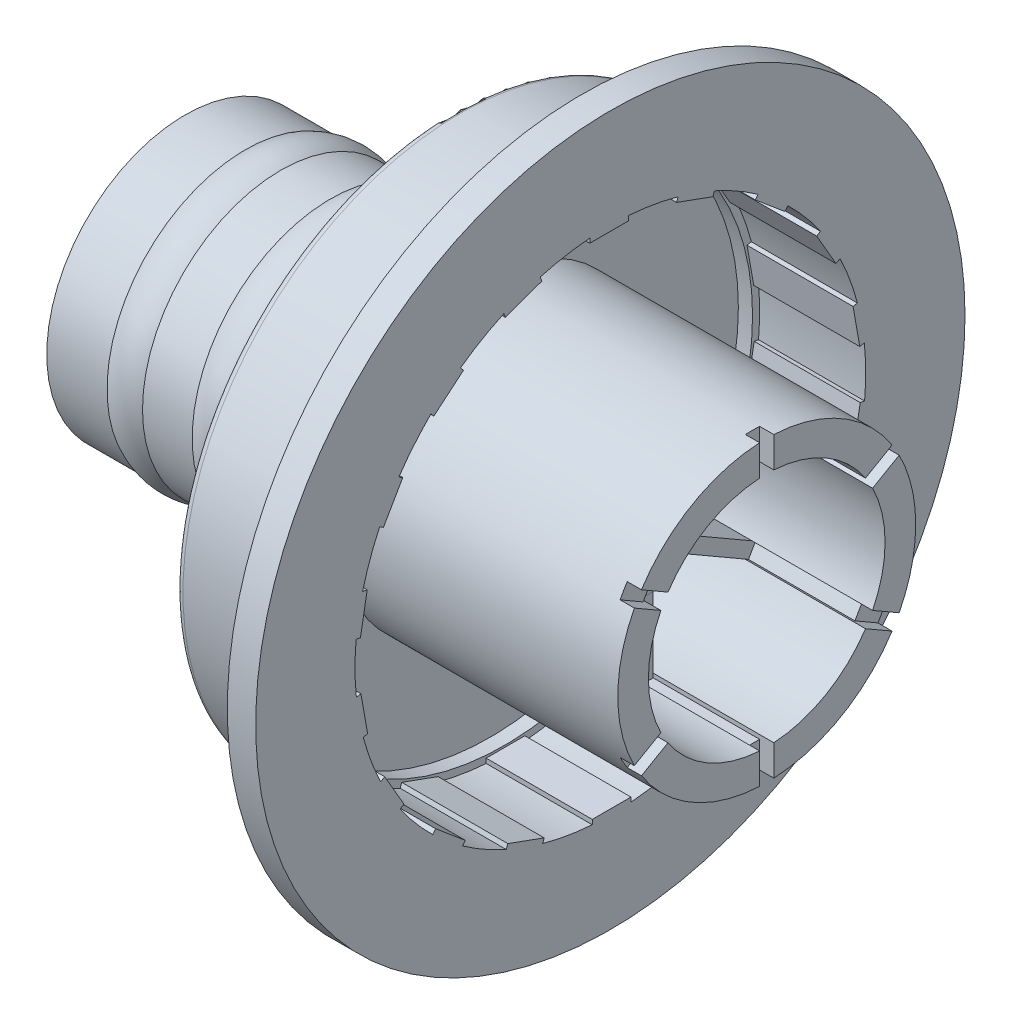
from build123d import *

# Parameters (mm, degrees)
FILLET1_R             = 0.254
SKETCH6_W             = 1.385253785
SKETCH6_H             = 0.18863488
BOSS_EXTRUDE2_DEPTH   = 4.306155
SKETCH9_R             = 9.144
SKETCH9_R_2           = 8.89
BOSS_EXTRUDE3_DEPTH   = 0.508
BOSS_EXTRUDE5_DEPTH   = 0.254
CIRPATTERN1_COUNT     = 6
SKETCH13_W            = 0.508
SKETCH13_H            = 0.321993029
CUT_EXTRUDE1_DEPTH    = 4.318
SKETCH15_W            = 0.508
SKETCH15_H            = 1.226289393
CUT_EXTRUDE2_DEPTH    = 0.508
BODY_MOVE_COPY1_ANGLE = 180


with BuildPart() as part:
    # Sketch1 → Revolve2 (revolve)
    with BuildSketch(Plane.XY):
        Polygon((0, 5.334), (9.906, 5.334), (9.906, 9.144), (5.59984456, 9.144), (5.59984456, 12.7), (6.61584456, 12.7), (6.61584456, 9.906), (11.2522, 9.906), (11.2522, 4.953), (20.828, 4.953), (20.828, 4.191), (7.5692, 4.191), (7.5692, 0.460290052), (6.35, 0.460290052), (6.35, 4.237756014), (0, 4.237756014), align=None)
    revolve(axis=Axis((-11.165471503, 0, 0), (1, 0, 0)))

    # Fillet1
    fillet1_edges = [part.edges().sort_by_distance(p)[0] for p in [
        (11.2522, -9.906, 0),
    ]]
    fillet(fillet1_edges, radius=FILLET1_R)

    # Sketch3 → Revolve3 (revolve)
    with BuildSketch(Plane.XY):
        with BuildLine():
            Line((18.669, 4.953), (17.399, 4.953))
            ThreePointArc((17.399, 4.953), (18.034, 5.094845226), (18.669, 4.953))
        make_face()
        with BuildLine():
            Line((15.621, 4.953), (14.351, 4.953))
            ThreePointArc((14.351, 4.953), (14.986, 5.094845226), (15.621, 4.953))
        make_face()
    revolve(axis=Axis((-9.458933626, 0, 0), (1, 0, 0)))

    # Sketch6 → Boss-Extrude2 (add)
    with BuildSketch(Plane.ZY.offset(-9.906)):
        with Locations((-0.044805356, 9.04968256)):
            Rectangle(SKETCH6_W, SKETCH6_H)
        Polygon((3.67166838, 8.193722505), (2.36995562, 8.667507203), (2.434472548, 8.844766008), (3.736185309, 8.370981309), align=None)
        Polygon((6.252657828, 6.443796029), (5.191491863, 7.334219999), (5.312744027, 7.4787227), (6.373909992, 6.58829873), align=None)
        Polygon((8.079484463, 3.916652652), (7.38685757, 5.116317621), (7.550220168, 5.210635061), (8.242847061, 4.010970091), align=None)
        Polygon((8.931806031, 0.917103161), (8.691259235, 2.281311829), (8.877028327, 2.314067932), (9.117575123, 0.949859264), align=None)
        Polygon((8.706819972, -2.193062506), (8.947366768, -0.828853838), (9.13313586, -0.861609941), (8.892589064, -2.225818609), align=None)
        Polygon((7.431662926, -5.038712469), (8.124289819, -3.839047499), (8.287652416, -3.933364939), (7.595025523, -5.133029909), align=None)
        Polygon((5.260137651, -7.276619344), (6.321303616, -6.386195374), (6.442555779, -6.530698076), (5.381389814, -7.421122045), align=None)
        Polygon((2.454162144, -8.636858535), (3.755874904, -8.163073837), (3.820391833, -8.340332641), (2.518679072, -8.81411734), align=None)
        with Locations((0.044805356, -9.04968256)):
            Rectangle(SKETCH6_W, SKETCH6_H)
        Polygon((-3.67166838, -8.193722505), (-2.36995562, -8.667507203), (-2.434472548, -8.844766008), (-3.736185309, -8.370981309), align=None)
        Polygon((-6.252657828, -6.443796029), (-5.191491863, -7.334219999), (-5.312744027, -7.4787227), (-6.373909992, -6.58829873), align=None)
        Polygon((-8.079484463, -3.916652652), (-7.38685757, -5.116317621), (-7.550220168, -5.210635061), (-8.242847061, -4.010970091), align=None)
        Polygon((-8.931806031, -0.917103161), (-8.691259235, -2.281311829), (-8.877028327, -2.314067932), (-9.117575123, -0.949859264), align=None)
        Polygon((-8.706819972, 2.193062506), (-8.947366768, 0.828853838), (-9.13313586, 0.861609941), (-8.892589064, 2.225818609), align=None)
        Polygon((-7.431662926, 5.038712469), (-8.124289819, 3.839047499), (-8.287652416, 3.933364939), (-7.595025523, 5.133029909), align=None)
        Polygon((-5.260137651, 7.276619344), (-6.321303616, 6.386195374), (-6.442555779, 6.530698076), (-5.381389814, 7.421122045), align=None)
        Polygon((-2.454162144, 8.636858535), (-3.755874904, 8.163073837), (-3.820391833, 8.340332641), (-2.518679072, 8.81411734), align=None)
    extrude(amount=BOSS_EXTRUDE2_DEPTH)

    # Sketch9 → Boss-Extrude3 (add)
    with BuildSketch(Plane.ZY.offset(-9.906)):
        Circle(SKETCH9_R)
        Circle(SKETCH9_R_2, mode=Mode.SUBTRACT)
    extrude(amount=BOSS_EXTRUDE3_DEPTH)

    # Sketch12 → Boss-Extrude5 (add, symmetric)
    with BuildSketch(Plane.XY):
        with BuildLine():
            Line((6.35, 0.935756014), (6.35, 4.237756014))
            Line((6.35, 4.237756014), (4.318, 4.237756014))
            Line((4.318, 4.237756014), (4.318, 1.697756014))
            ThreePointArc((4.318, 1.697756014), (4.541184633, 1.158940646), (5.08, 0.935756014))
            Line((5.08, 0.935756014), (6.35, 0.935756014))
        make_face()
    boss_extrude5 = extrude(amount=BOSS_EXTRUDE5_DEPTH, both=True)

    # CirPattern1: Boss-Extrude5 ×6 about axis
    cirpattern1_axis = Axis((0, 0, 0), (1, 0, 0))
    for i in range(1, CIRPATTERN1_COUNT):
        add(boss_extrude5.rotate(cirpattern1_axis, i * 360 / CIRPATTERN1_COUNT))

    # Sketch13 → Cut-Extrude1 (cut)
    with BuildSketch(Plane.ZY):
        with Locations((0, 4.217301472)):
            Rectangle(SKETCH13_W, SKETCH13_H)
        Polygon((3.385863139, 2.248122932), (3.664717282, 2.409119446), (3.918717282, 1.969178541), (3.639863139, 1.808182026), align=None)
        Polygon((3.639863139, -1.808182026), (3.918717282, -1.969178541), (3.664717282, -2.409119446), (3.385863139, -2.248122932), align=None)
        with Locations((0, -4.217301472)):
            Rectangle(SKETCH13_W, SKETCH13_H)
        Polygon((-3.385863139, -2.248122932), (-3.664717282, -2.409119446), (-3.918717282, -1.969178541), (-3.639863139, -1.808182026), align=None)
        Polygon((-3.639863139, 1.808182026), (-3.918717282, 1.969178541), (-3.664717282, 2.409119446), (-3.385863139, 2.248122932), align=None)
    extrude(amount=-CUT_EXTRUDE1_DEPTH, mode=Mode.SUBTRACT)

    # Sketch15 → Cut-Extrude2 (cut)
    with BuildSketch(Plane.ZY):
        with Locations((0, 4.843281813)):
            Rectangle(SKETCH15_W, SKETCH15_H)
        Polygon((3.536406205, 2.335039011), (4.598403971, 2.948183708), (4.852403971, 2.508242802), (3.790406205, 1.895098106), align=None)
        Polygon((3.790406205, -1.895098106), (4.852403971, -2.508242802), (4.598403971, -2.948183708), (3.536406205, -2.335039011), align=None)
        with Locations((0, -4.843281813)):
            Rectangle(SKETCH15_W, SKETCH15_H)
        Polygon((-3.536406205, -2.335039011), (-4.598403971, -2.948183708), (-4.852403971, -2.508242802), (-3.790406205, -1.895098106), align=None)
        Polygon((-3.790406205, 1.895098106), (-4.852403971, 2.508242802), (-4.598403971, 2.948183708), (-3.536406205, 2.335039011), align=None)
    extrude(amount=-CUT_EXTRUDE2_DEPTH, mode=Mode.SUBTRACT)


with BuildPart() as part_1:
    # Body-Move/Copy1: moved
    add(part.part.rotate(Axis((10.414, 0, 0), (0, 1, 0)), BODY_MOVE_COPY1_ANGLE))


solid = part_1.part
